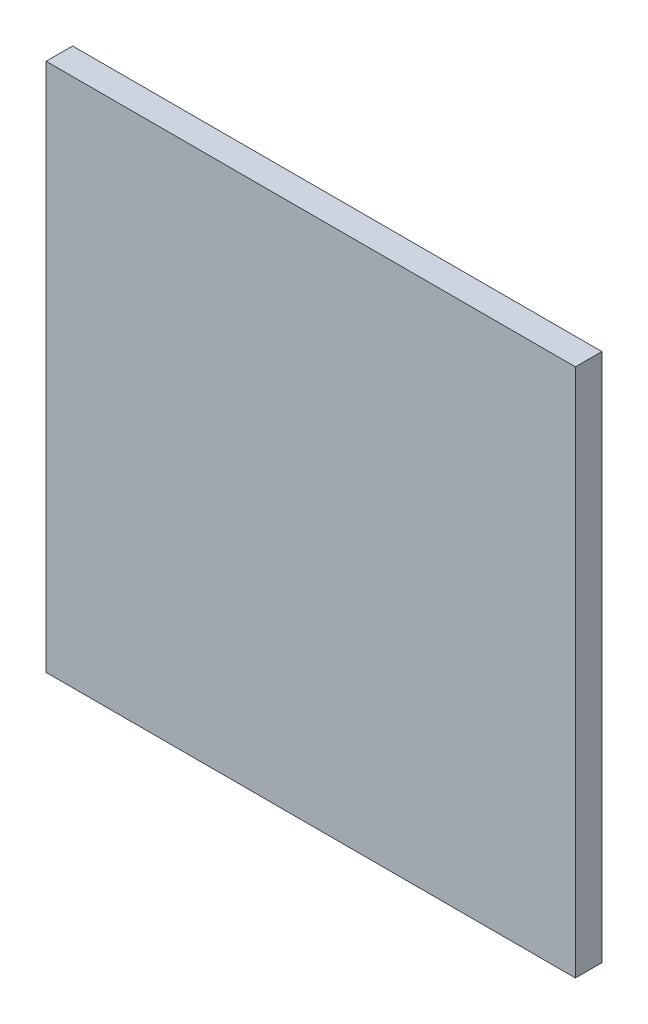
from build123d import *

# Parameters (mm, degrees)
SKETCH1_W           = 25.4
SKETCH1_H           = 25.4
BOSS_EXTRUDE1_DEPTH = 1.27


with BuildPart() as part:
    # Sketch1 → Boss-Extrude1 (new body)
    with BuildSketch(Plane(origin=(0, 0, 0), x_dir=(0, 1, 0), z_dir=(0, 0, 1))):
        with Locations((12.7, 12.7)):
            Rectangle(SKETCH1_W, SKETCH1_H)
    extrude(amount=BOSS_EXTRUDE1_DEPTH)


solid = part.part
